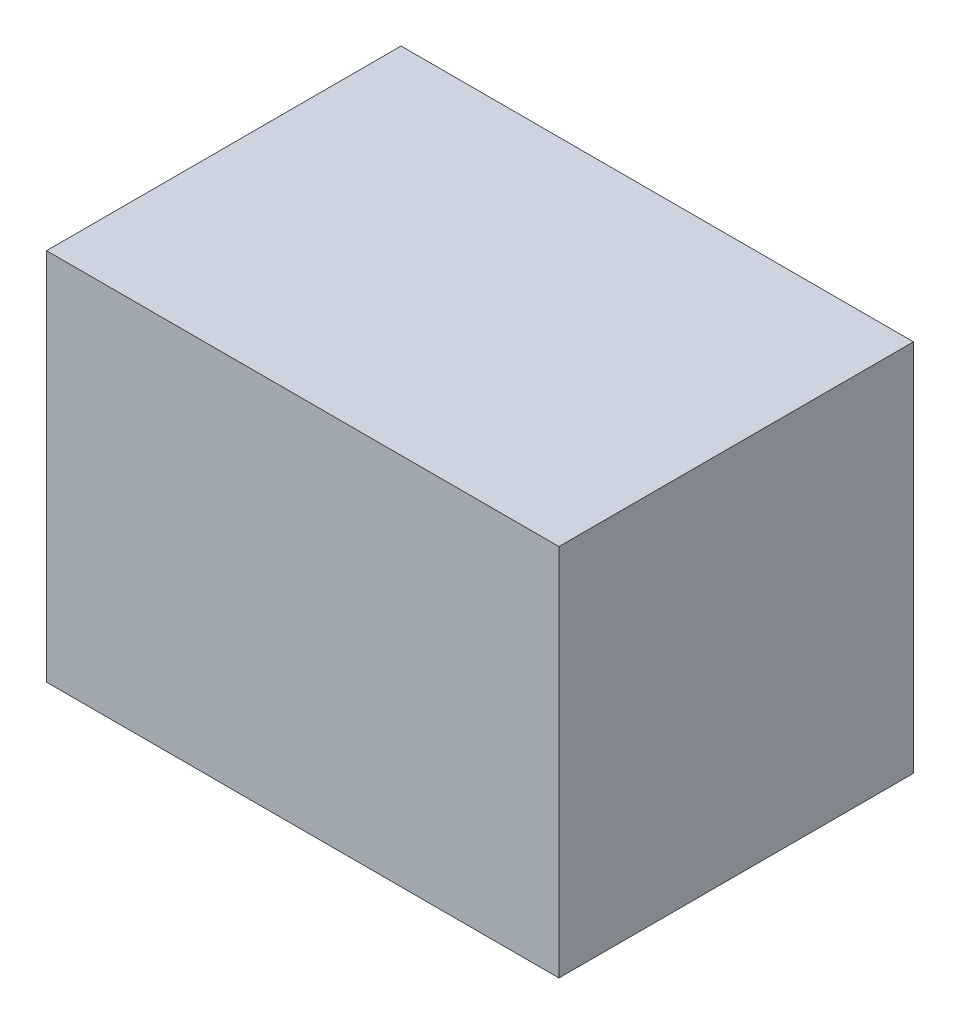
from build123d import *

# Parameters (mm, degrees)
SKETCH1_W           = 48
SKETCH1_H           = 33.209
BOSS_EXTRUDE1_DEPTH = 35


with BuildPart() as part:
    # Sketch1 → Boss-Extrude1 (new body)
    with BuildSketch(Plane(origin=(0, 0, 0), x_dir=(1, 0, 0), z_dir=(0, 1, 0))):
        Rectangle(SKETCH1_W, SKETCH1_H)
    extrude(amount=BOSS_EXTRUDE1_DEPTH)


solid = part.part
